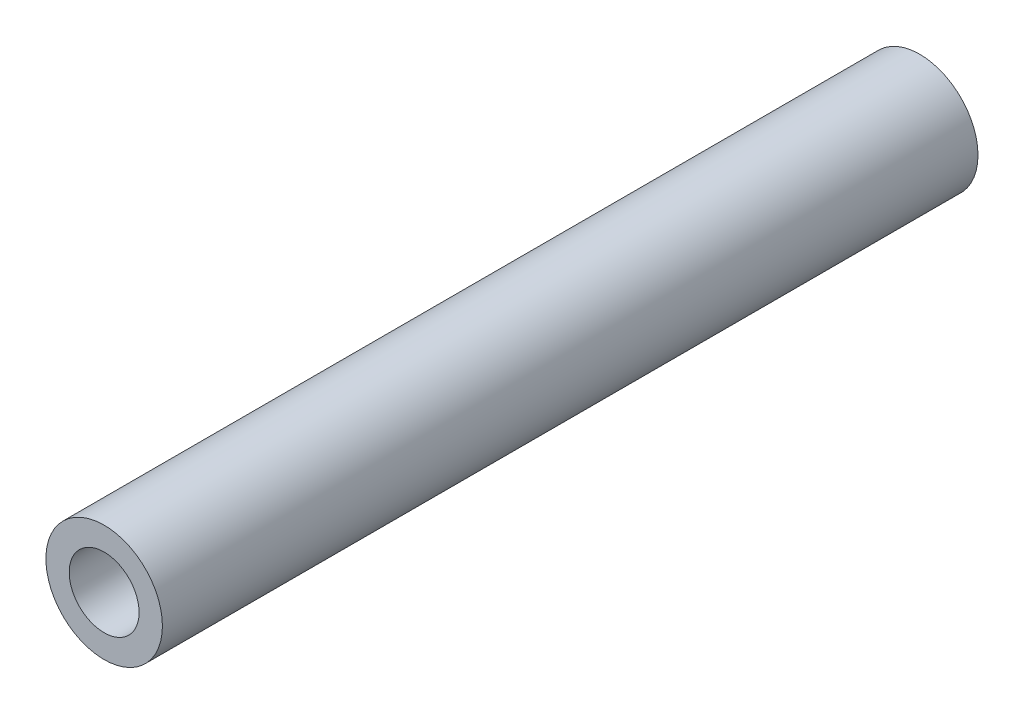
from build123d import *

# Parameters (mm, degrees)
SKETCH1_R           = 2.5
SKETCH1_R_2         = 1.5
BOSS_EXTRUDE2_DEPTH = 35


with BuildPart() as part:
    # Sketch1 → Boss-Extrude2 (new body)
    with BuildSketch(Plane.XY):
        Circle(SKETCH1_R)
        Circle(SKETCH1_R_2, mode=Mode.SUBTRACT)
    extrude(amount=BOSS_EXTRUDE2_DEPTH)


solid = part.part
